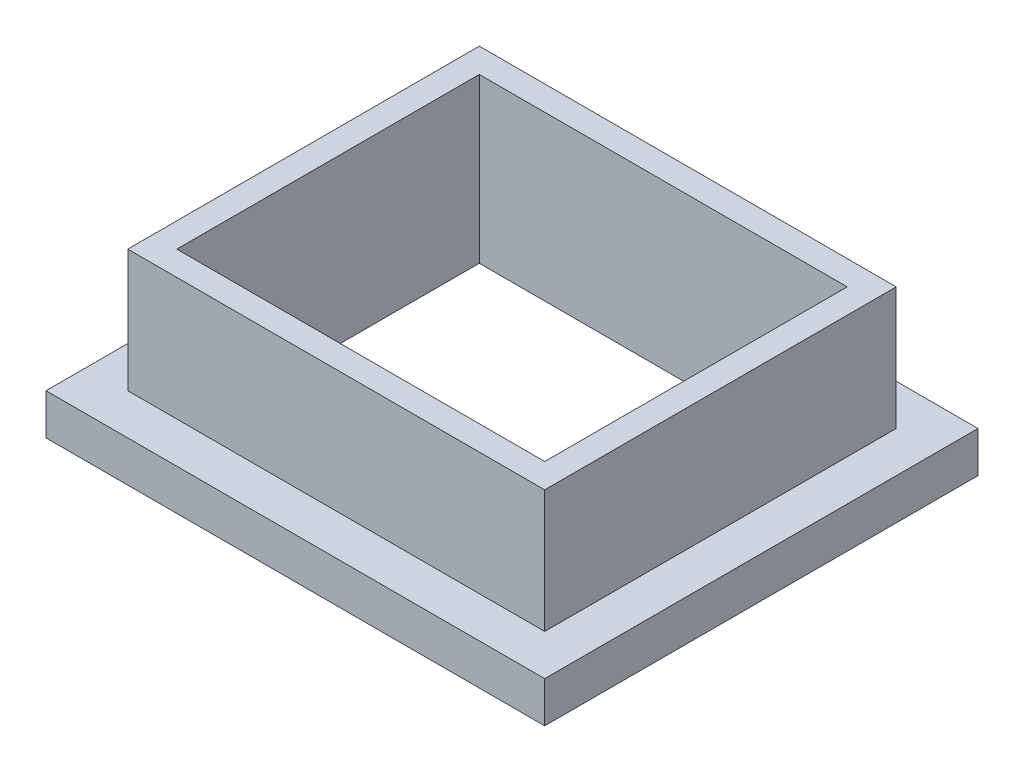
from build123d import *

# Parameters (mm, degrees)
SKETCH2_W           = 61
SKETCH2_H           = 53
SKETCH2_W_2         = 51
SKETCH2_H_2         = 43
BOSS_EXTRUDE1_DEPTH = 5
SKETCH6_W           = 51
SKETCH6_H           = 43
SKETCH6_W_2         = 45
SKETCH6_H_2         = 37
BOSS_EXTRUDE3_DEPTH = 20


with BuildPart() as part:
    # Sketch2 → Boss-Extrude1 (new body)
    with BuildSketch(Plane(origin=(0, 0, 0), x_dir=(1, 0, 0), z_dir=(0, 1, 0))):
        with Locations((30.5, 26.5)):
            Rectangle(SKETCH2_W, SKETCH2_H)
        with Locations((30.5, 26.5)):
            Rectangle(SKETCH2_W_2, SKETCH2_H_2, mode=Mode.SUBTRACT)
    extrude(amount=BOSS_EXTRUDE1_DEPTH)

    # Sketch6 → Boss-Extrude3 (add)
    with BuildSketch(Plane(origin=(0, 0, 0), x_dir=(1, 0, 0), z_dir=(0, 1, 0))):
        with Locations((30.5, 26.5)):
            Rectangle(SKETCH6_W, SKETCH6_H)
        with Locations((30.5, 26.5)):
            Rectangle(SKETCH6_W_2, SKETCH6_H_2, mode=Mode.SUBTRACT)
    extrude(amount=BOSS_EXTRUDE3_DEPTH)


solid = part.part
